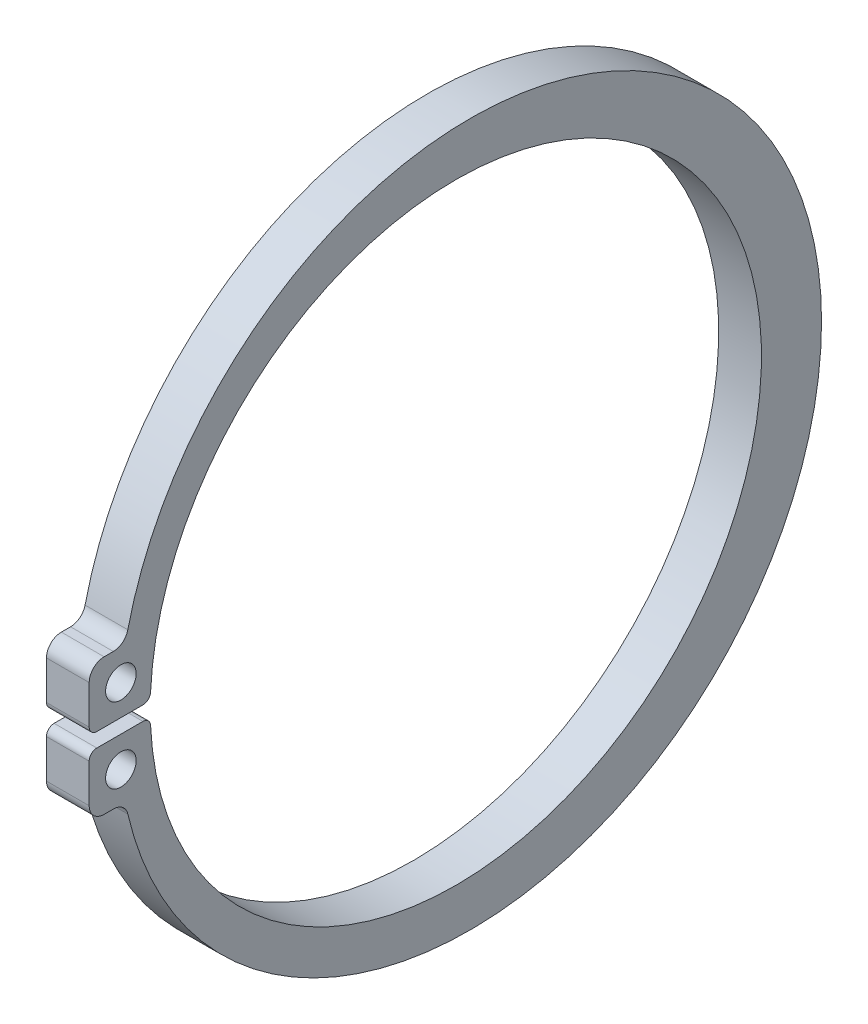
from build123d import *

# Parameters (mm, degrees)
SKETCH_1_R      = 0.3575
EXTRUDE_1_DEPTH = 1


with BuildPart() as part:
    # Эскиз1 → Бобышка-Вытянуть1 (new body)
    with BuildSketch(Plane(origin=(-34, 0, 0), x_dir=(0, -1, 0), z_dir=(-1, 0, 0))):
        with BuildLine():
            Line((-8.389166667, -1.257451802), (-8.389166667, -0.17875))
            ThreePointArc((-8.389166667, -0.17875), (-8.44152133, -0.052354663), (-8.567916667, 0))
            Line((-8.567916667, 0), (-9.470386179, 0))
            ThreePointArc((-9.470386179, 0), (-9.717011227, -0.10215544), (-9.819166667, -0.348780488))
            Line((-9.819166667, -0.348780488), (-9.819166667, -0.563811004))
            ThreePointArc((-9.819166667, -0.563811004), (-9.894763543, -0.7806486), (-10.088783486, -0.903488707))
            ThreePointArc((-10.088783486, -0.903488707), (-8.2225, -17.133890567), (-6.356216514, -0.903488707))
            ThreePointArc((-6.356216514, -0.903488707), (-6.550236457, -0.7806486), (-6.625833333, -0.563811004))
            Line((-6.625833333, -0.563811004), (-6.625833333, -0.348780488))
            ThreePointArc((-6.625833333, -0.348780488), (-6.727988773, -0.10215544), (-6.974613821, 0))
            Line((-6.974613821, 0), (-7.877083333, 0))
            ThreePointArc((-7.877083333, 0), (-8.00347867, -0.052354663), (-8.055833333, -0.17875))
            Line((-8.055833333, -0.17875), (-8.055833333, -1.257451802))
            ThreePointArc((-8.055833333, -1.257451802), (-8.006422993, -1.380832575), (-7.88550813, -1.436003154))
            ThreePointArc((-7.88550813, -1.436003154), (-8.2225, -15.728057234), (-8.55949187, -1.436003154))
            ThreePointArc((-8.55949187, -1.436003154), (-8.438577007, -1.380832575), (-8.389166667, -1.257451802))
        make_face()
        with Locations((-9.104166667, -0.741312313)):
            Circle(SKETCH_1_R, mode=Mode.SUBTRACT)
        with Locations((-7.340833333, -0.741312313)):
            Circle(SKETCH_1_R, mode=Mode.SUBTRACT)
    extrude(amount=-EXTRUDE_1_DEPTH)


solid = part.part
